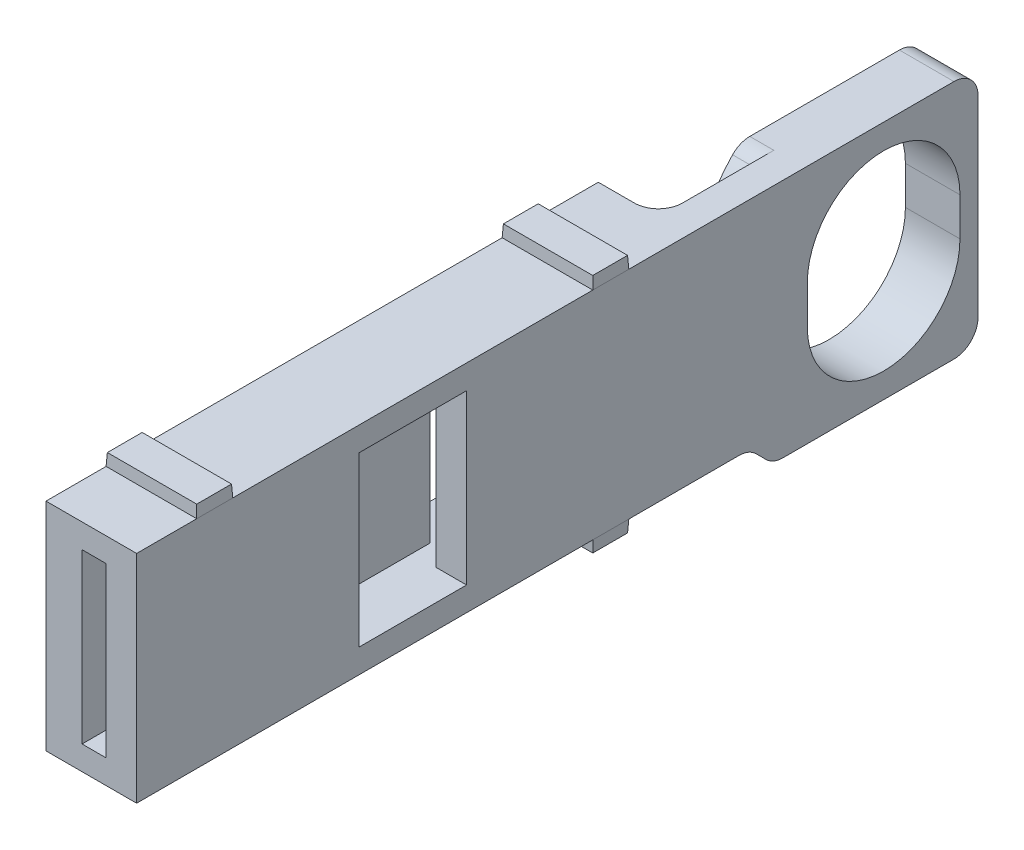
from build123d import *

# Parameters (mm, degrees)
EXTRUDE1_DEPTH     = 2.54
EXTRUDE2_DEPTH     = 2
SKETCH4_W          = 45.95
SKETCH4_H          = 18
SKETCH4_W_2        = 41.95
SKETCH4_H_2        = 14
EXTRUDE3_DEPTH     = 5
SKETCH5_W          = 11.95
SKETCH5_H          = 14
EXTRUDE4_DEPTH     = 5
SKETCH6_W          = 2
SKETCH6_H          = 14
CUT_EXTRUDE1_DEPTH = 43.95
CUT_EXTRUDE2_REACH = 9.54
SKETCH7_W          = 8.95
SKETCH7_H          = 14
FILLET1_R          = 2
SKETCH8_W          = 7.54
SKETCH8_H          = 3
EXTRUDE5_DEPTH     = 1
EXTRUDE5_TAPER     = 3
SKETCH9_W          = 7.54
SKETCH9_H          = 3
EXTRUDE6_DEPTH     = 1
EXTRUDE6_TAPER     = 3


with BuildPart() as part:
    # Sketch1 → Extrude1 (new body)
    with BuildSketch(Plane(origin=(0, 0, 0), x_dir=(0, 0, -1), z_dir=(1, 0, 0))):
        Polygon((-62.15, 10), (7.85, 10), (7.85, -10), (-9.2, -10), (-11.2, -8), (-62.15, -8), align=None)
        with BuildLine():
            Line((-6.35, 1.5875), (-6.35, -1.5875))
            ThreePointArc((-6.35, -1.5875), (0, -7.9375), (6.35, -1.5875))
            Line((6.35, -1.5875), (6.35, 1.5875))
            ThreePointArc((6.35, 1.5875), (0, 7.9375), (-6.35, 1.5875))
        make_face(mode=Mode.SUBTRACT)
    extrude(amount=EXTRUDE1_DEPTH)

    # Sketch3 → Extrude2 (add)
    with BuildSketch(Plane.ZY):
        with BuildLine():
            Line((11.2, -8), (11.200000082, 1.5875))
            ThreePointArc((11.200000082, 1.5875), (10.204208676, 6.204222555), (7.393905977, 10))
            Line((7.393905977, 10), (-7.85, 10))
            Line((-7.85, 10), (-7.85, -10))
            Line((-7.85, -10), (9.2, -10))
            Line((9.2, -10), (11.2, -8))
        make_face()
        with BuildLine():
            Line((6.35, 1.5875), (6.35, -1.5875))
            ThreePointArc((6.35, -1.5875), (0, -7.9375), (-6.35, -1.5875))
            Line((-6.35, -1.5875), (-6.35, 1.5875))
            ThreePointArc((-6.35, 1.5875), (0, 7.9375), (6.35, 1.5875))
        make_face(mode=Mode.SUBTRACT)
    extrude(amount=EXTRUDE2_DEPTH)

    # Sketch4 → Extrude3 (add)
    with BuildSketch(Plane.ZY):
        with Locations((39.175, 1)):
            Rectangle(SKETCH4_W, SKETCH4_H)
        with Locations((39.175, 1)):
            Rectangle(SKETCH4_W_2, SKETCH4_H_2, mode=Mode.SUBTRACT)
    extrude(amount=EXTRUDE3_DEPTH)

    # Sketch5 → Extrude4 (add)
    with BuildSketch(Plane.ZY):
        with Locations((39.175, 1)):
            Rectangle(SKETCH5_W, SKETCH5_H)
    extrude(amount=EXTRUDE4_DEPTH)

    # Sketch6 → Cut-Extrude1 (cut)
    with BuildSketch(Plane.XY.offset(62.15)):
        with Locations((-1, 1)):
            Rectangle(SKETCH6_W, SKETCH6_H)
    extrude(amount=-CUT_EXTRUDE1_DEPTH, mode=Mode.SUBTRACT)

    # Sketch7 → Cut-Extrude2 (cut, up to next)
    with BuildSketch(Plane(origin=(2.54, 0, 0), x_dir=(0, 0, -1), z_dir=(1, 0, 0)), mode=Mode.PRIVATE) as cut_extrude2_sk1:
        with Locations((-39.175, 1)):
            Rectangle(SKETCH7_W, SKETCH7_H)
    cut_extrude2_tool1 = extrude(cut_extrude2_sk1.sketch, amount=-CUT_EXTRUDE2_REACH, mode=Mode.PRIVATE) & part.part
    add(cut_extrude2_tool1.solids().sort_by_distance((2.54, 1, 39.175))[0], mode=Mode.SUBTRACT)

    # Fillet1
    fillet1_edges = [part.edges().sort_by_distance(p)[0] for p in [
        (0.27, 10, -7.85),
        (0.27, -10, -7.85),
        (0.27, -10, 9.2),
        (1.27, -8, 11.2),
        (-1, 10, 7.393905977),
        (0, 1, 16.2),
    ]]
    fillet(fillet1_edges, radius=FILLET1_R)

    # Sketch8 → Extrude5 (add)
    with BuildSketch(Plane(origin=(0, 10, 0), x_dir=(1, 0, 0), z_dir=(0, 1, 0))):
        with Locations((-1.23, -22.7)):
            Rectangle(SKETCH8_W, SKETCH8_H)
        with Locations((-1.23, -55.65)):
            Rectangle(SKETCH8_W, SKETCH8_H)
    extrude(amount=EXTRUDE5_DEPTH, taper=EXTRUDE5_TAPER)

    # Sketch9 → Extrude6 (add)
    with BuildSketch(Plane.XZ.offset(8)):
        with Locations((-1.23, 22.7)):
            Rectangle(SKETCH9_W, SKETCH9_H)
    extrude(amount=EXTRUDE6_DEPTH, taper=EXTRUDE6_TAPER)


solid = part.part
